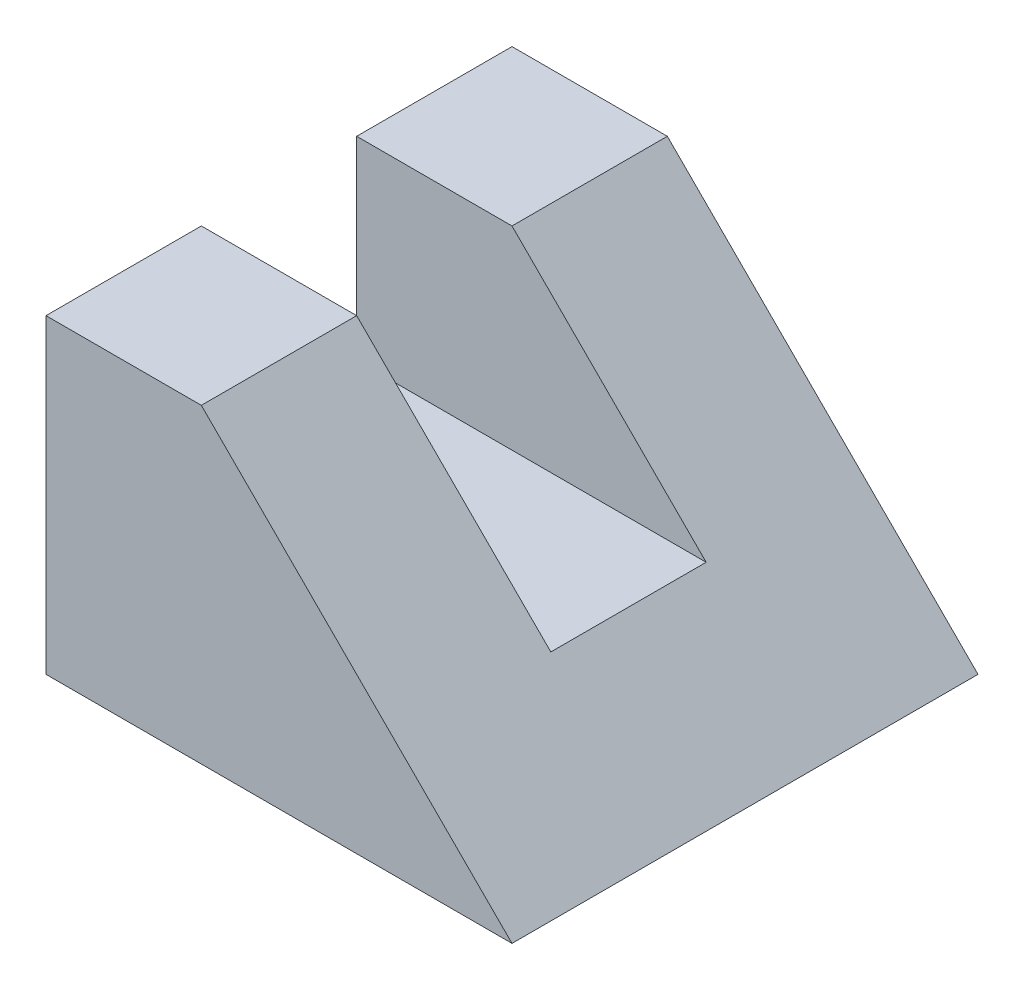
from build123d import *

# Parameters (mm, degrees)
BOSS_EXTRUDE1_DEPTH = 300
SKETCH2_W           = 600
SKETCH2_H           = 100
CUT_EXTRUDE1_DEPTH  = 250


with BuildPart() as part:
    # Sketch1 → Boss-Extrude1 (new body)
    with BuildSketch(Plane.XY):
        Polygon((-300, 400), (-300, 0), (300, 0), (-100, 400), align=None)
    boss_extrude1 = extrude(amount=BOSS_EXTRUDE1_DEPTH)

    # Sketch2 → Cut-Extrude1 (cut)
    with BuildSketch(Plane(origin=(0, 400, 0), x_dir=(1, 0, 0), z_dir=(0, 1, 0))):
        with Locations((0, -50)):
            Rectangle(SKETCH2_W, SKETCH2_H)
    cut_extrude1 = extrude(amount=-CUT_EXTRUDE1_DEPTH, mode=Mode.SUBTRACT)

    # Mirror1: Boss-Extrude1, Cut-Extrude1 across plane
    add(boss_extrude1.mirror(Plane.XY))
    add(cut_extrude1.mirror(Plane.XY), mode=Mode.SUBTRACT)


solid = part.part
